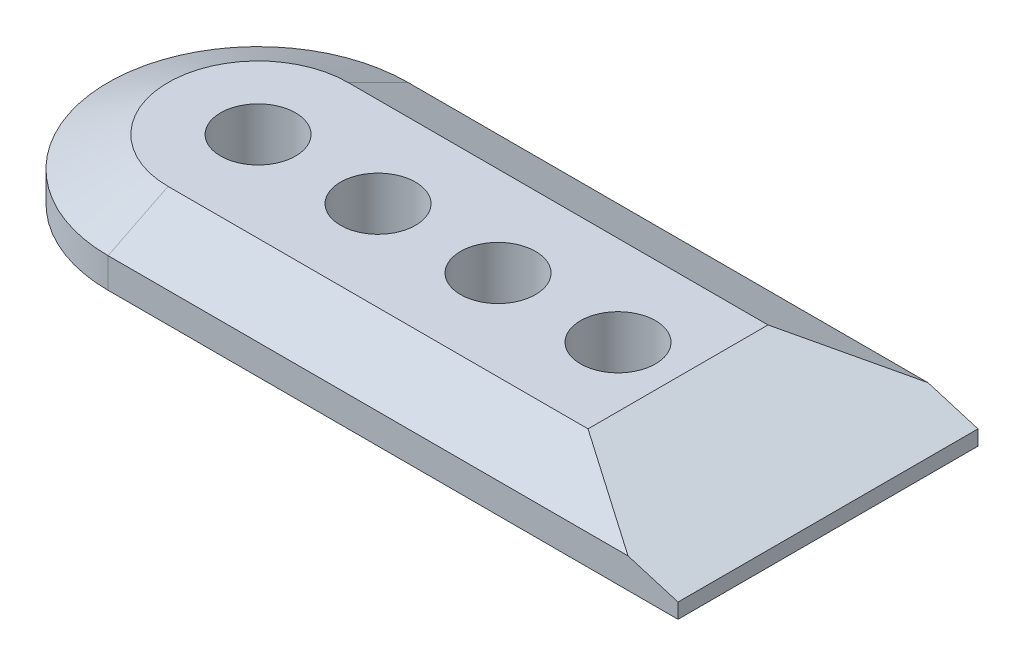
from build123d import *
from OCP.BRepFilletAPI import BRepFilletAPI_MakeChamfer

# Parameters (mm, degrees)
BOSS_EXTRUDE2_DEPTH = 12.7
CHAMFER3_SIZE       = 6.35
CHAMFER3_SIZE2      = 12.7
CHAMFER4_SIZE       = 9.525
CHAMFER4_SIZE2      = 31.75
SKETCH14_R          = 7.9375
CUT_EXTRUDE3_DEPTH  = 126.402452129


with BuildPart() as part:
    # Sketch13 → Boss-Extrude2 (new body)
    with BuildSketch(Plane(origin=(0, 0, 0), x_dir=(1, 0, 0), z_dir=(0, 1, 0))):
        with BuildLine():
            Line((0, 31.75), (120.65, 31.75))
            Line((120.65, 31.75), (120.65, -31.75))
            Line((120.65, -31.75), (0, -31.75))
            ThreePointArc((0, -31.75), (-31.75, 0), (0, 31.75))
        make_face()
    extrude(amount=BOSS_EXTRUDE2_DEPTH)

    # Chamfer3: one chamfer whose edges measure the first distance from different faces: ONE call of the kernel's chamfer builder (chamfer() names one face for all edges)
    chamfer3_edges_1 = [part.edges().sort_by_distance(p)[0] for p in [
        (60.325, 12.7, -31.75),
    ]]
    chamfer3_side_1 = [part.faces().sort_by_distance(p)[0] for p in [
        (60.325, 6.35, -31.75),
    ]]
    chamfer3_edges_2 = [part.edges().sort_by_distance(p)[0] for p in [
        (-31.75, 12.7, 0),
    ]]
    chamfer3_side_2 = [part.faces().sort_by_distance(p)[0] for p in [
        (-31.75, 6.35, 0),
    ]]
    chamfer3_edges_3 = [part.edges().sort_by_distance(p)[0] for p in [
        (60.325, 12.7, 31.75),
    ]]
    chamfer3_side_3 = [part.faces().sort_by_distance(p)[0] for p in [
        (60.325, 6.35, 31.75),
    ]]
    chamfer3 = BRepFilletAPI_MakeChamfer(part.part.solid().wrapped)
    for e in chamfer3_edges_1:
        chamfer3.Add(CHAMFER3_SIZE, CHAMFER3_SIZE2, e.wrapped, chamfer3_side_1[0].wrapped)  # the first distance lies on this face
    for e in chamfer3_edges_2:
        chamfer3.Add(CHAMFER3_SIZE, CHAMFER3_SIZE2, e.wrapped, chamfer3_side_2[0].wrapped)  # the first distance lies on this face
    for e in chamfer3_edges_3:
        chamfer3.Add(CHAMFER3_SIZE, CHAMFER3_SIZE2, e.wrapped, chamfer3_side_3[0].wrapped)  # the first distance lies on this face
    add(Compound.cast(chamfer3.Shape()), mode=Mode.REPLACE)

    # Chamfer4
    chamfer4_edges = [part.edges().sort_by_distance(p)[0] for p in [
        (120.65, 12.7, 0),
    ]]
    chamfer4_side = [part.faces().sort_by_distance(p)[0] for p in [
        (120.65, 5.87962963, 0),
    ]]
    chamfer(chamfer4_edges, length=CHAMFER4_SIZE, length2=CHAMFER4_SIZE2, reference=chamfer4_side[0])

    # Sketch14 → Cut-Extrude3 (cut, through all)
    with BuildSketch(Plane(origin=(0, 12.7, 0), x_dir=(1, 0, 0), z_dir=(0, 1, 0))):
        with Locations(Location((0, 0, 0), (0, 0, 270))):
            Circle(SKETCH14_R)
        with Locations(Location((25.4, 0, 0), (0, 0, 270))):
            Circle(SKETCH14_R)
        with Locations(Location((50.8, 0, 0), (0, 0, 270))):
            Circle(SKETCH14_R)
        with Locations(Location((76.2, 0, 0), (0, 0, 270))):
            Circle(SKETCH14_R)
    extrude(amount=-CUT_EXTRUDE3_DEPTH, mode=Mode.SUBTRACT)


solid = part.part
